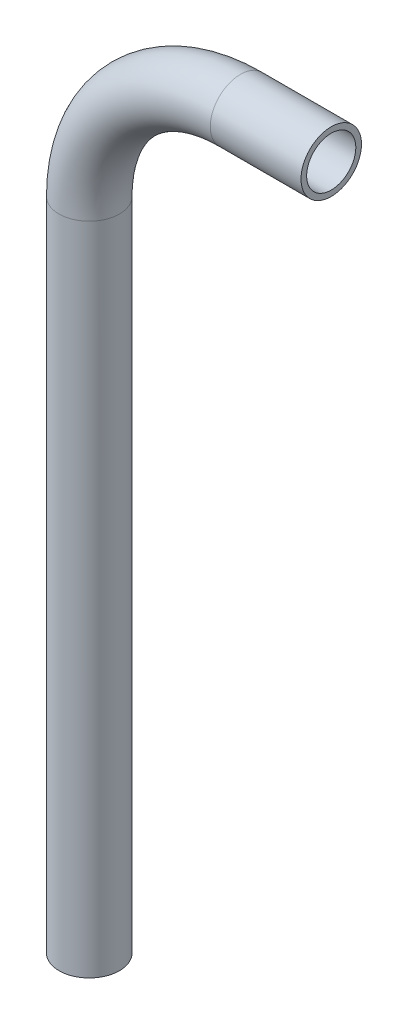
from build123d import *

# Parameters (mm, degrees)
SKETCH2_R   = 4.7625
SKETCH2_R_2 = 3.8735


with BuildPart() as part:
    # Sweep1: sweep along a path in Sketch1
    with BuildLine(Plane.XY) as sweep1_path:
        Line((0, -127), (0, -23.8125))
        ThreePointArc((0, -23.8125), (6.974519773, -6.974519773), (23.8125, 0))
        Line((23.8125, 0), (38.1, 0))
    # Sketch2 → Sweep1 (sweep)
    with BuildSketch(Plane(origin=(38.1, 0, 0), x_dir=(0, 0, -1), z_dir=(1, 0, 0))):
        Circle(SKETCH2_R)
        Circle(SKETCH2_R_2, mode=Mode.SUBTRACT)
    sweep(path=sweep1_path.line)


solid = part.part
